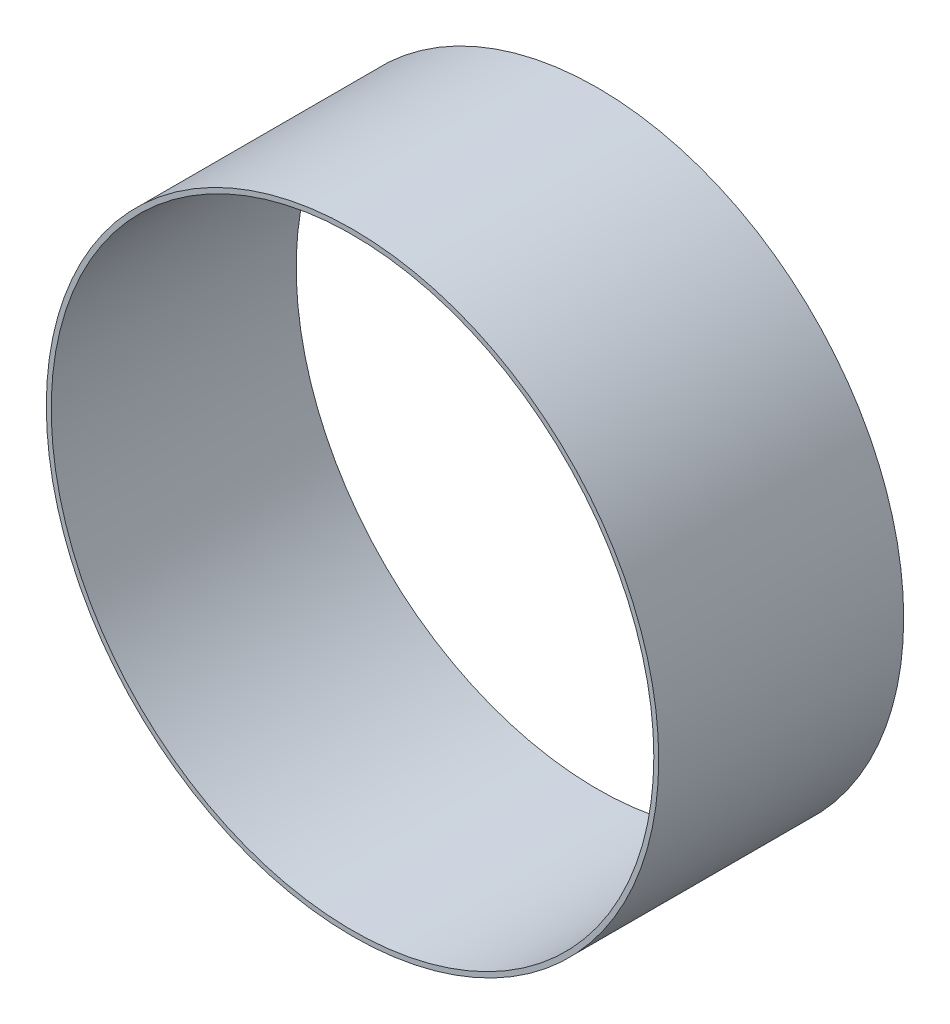
from build123d import *

# Parameters (mm, degrees)
SKETCH_1_R      = 125
SKETCH_1_R_2    = 123
EXTRUDE_1_DEPTH = 100


with BuildPart() as part:
    # 草图1 → 凸台-拉伸1 (new body)
    with BuildSketch(Plane.XY):
        Circle(SKETCH_1_R)
        Circle(SKETCH_1_R_2, mode=Mode.SUBTRACT)
    extrude(amount=EXTRUDE_1_DEPTH)


solid = part.part
